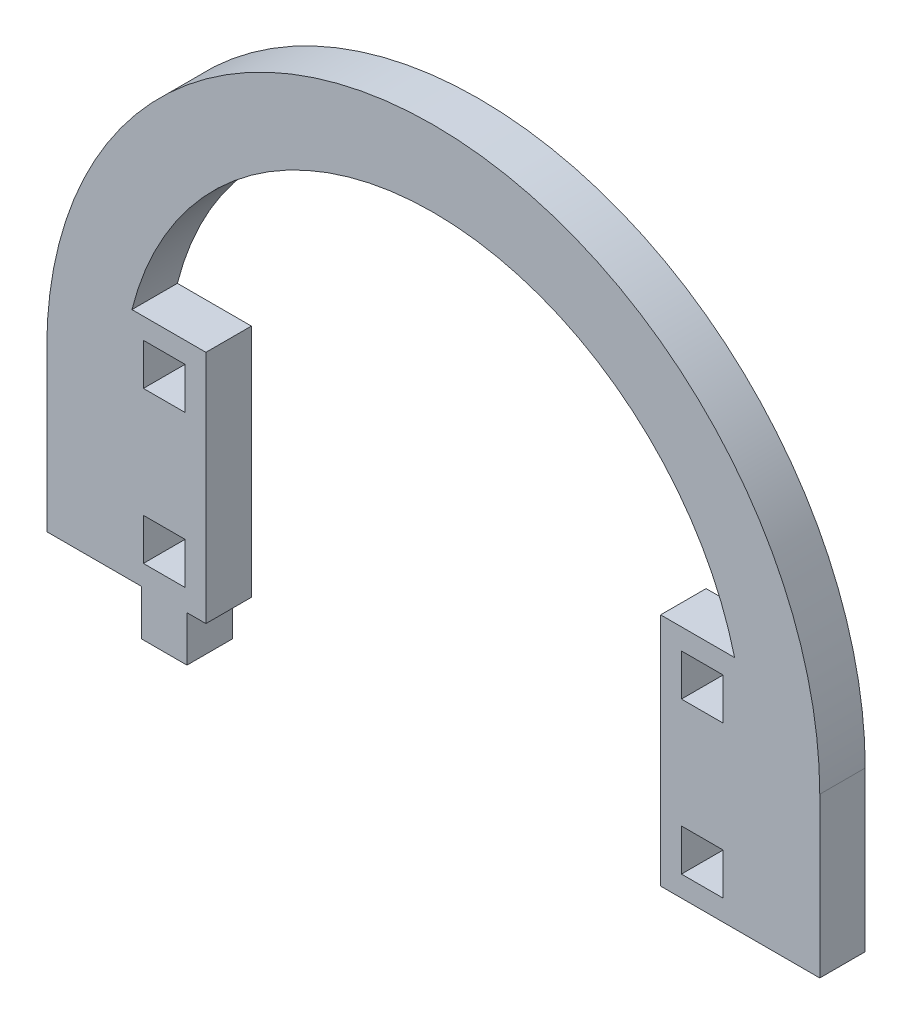
from build123d import *

# Parameters (mm, degrees)
MODEL_W             = 5.5
MODEL_H             = 5.5
BOSS_EXTRUDE1_DEPTH = 6


with BuildPart() as part:
    # Model → Boss-Extrude1 (new body)
    with BuildSketch(Plane.XY):
        with BuildLine():
            Line((3413.843002063, 1402.049969321), (3413.843002063, 1381.049969321))
            Line((3413.843002063, 1381.049969321), (3426.343002063, 1381.049969321))
            Line((3426.343002063, 1381.049969321), (3426.343002063, 1375.049969321))
            Line((3426.343002063, 1375.049969321), (3432.343002063, 1375.049969321))
            Line((3432.343002063, 1375.049969321), (3432.343002063, 1381.049969321))
            Line((3432.343002063, 1381.049969321), (3434.843002063, 1381.049969321))
            Line((3434.843002063, 1381.049969321), (3434.843002063, 1412.049969321))
            Line((3434.843002063, 1412.049969321), (3425.081211359, 1412.049969321))
            ThreePointArc((3425.081211359, 1412.049969321), (3464.843002063, 1443.049969321), (3504.604792768, 1412.049969321))
            Line((3504.604792768, 1412.049969321), (3494.843002063, 1412.049969321))
            Line((3494.843002063, 1412.049969321), (3494.843002063, 1381.049969321))
            Line((3494.843002063, 1381.049969321), (3505.843002063, 1381.049969321))
            Line((3505.843002063, 1381.049969321), (3515.843002063, 1381.049969321))
            Line((3515.843002063, 1381.049969321), (3515.843002063, 1402.049969321))
            ThreePointArc((3515.843002063, 1402.049969321), (3464.843002063, 1453.049969321), (3413.843002063, 1402.049969321))
        make_face()
        with Locations((3500.343002063, 1386.549969321)):
            Rectangle(MODEL_W, MODEL_H, mode=Mode.SUBTRACT)
        with Locations((3500.343002063, 1406.549969321)):
            Rectangle(MODEL_W, MODEL_H, mode=Mode.SUBTRACT)
        with Locations((3429.343002063, 1386.549969321)):
            Rectangle(MODEL_W, MODEL_H, mode=Mode.SUBTRACT)
        with Locations((3429.343002063, 1406.549969321)):
            Rectangle(MODEL_W, MODEL_H, mode=Mode.SUBTRACT)
    extrude(amount=BOSS_EXTRUDE1_DEPTH)


solid = part.part
